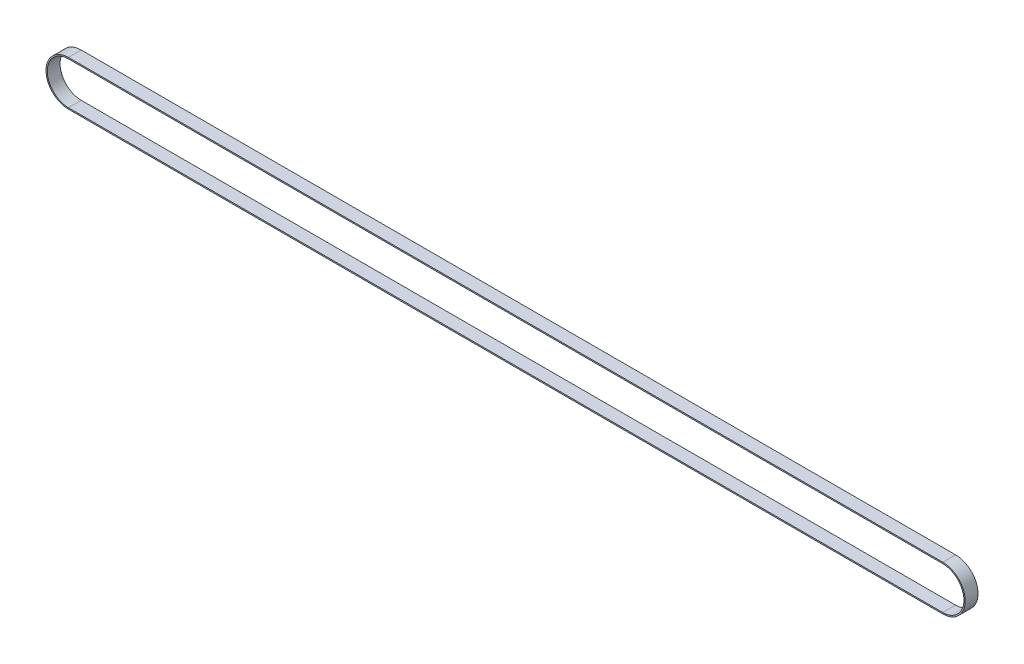
from build123d import *

# Parameters (mm, degrees)
BOSS_EXTRUDE2_DEPTH = 20
CUT_EXTRUDE3_DEPTH  = 20


with BuildPart() as part:
    # Sketch1 → Boss-Extrude2 (new body)
    with BuildSketch(Plane.XY):
        with BuildLine():
            Line((0, 35), (1365, 35))
            ThreePointArc((1365, 35), (1400, 0), (1365, -35))
            Line((1365, -35), (0, -35))
            ThreePointArc((0, -35), (-35, 0), (0, 35))
        make_face()
    extrude(amount=BOSS_EXTRUDE2_DEPTH)

    # Sketch3 → Cut-Extrude3 (cut)
    with BuildSketch(Plane.XY.offset(20)):
        with BuildLine():
            Line((0, 33), (1365, 33))
            ThreePointArc((1365, 33), (1398, 0), (1365, -33))
            Line((1365, -33), (0, -33))
            ThreePointArc((0, -33), (-33, 0), (0, 33))
        make_face()
    extrude(amount=-CUT_EXTRUDE3_DEPTH, mode=Mode.SUBTRACT)


solid = part.part
